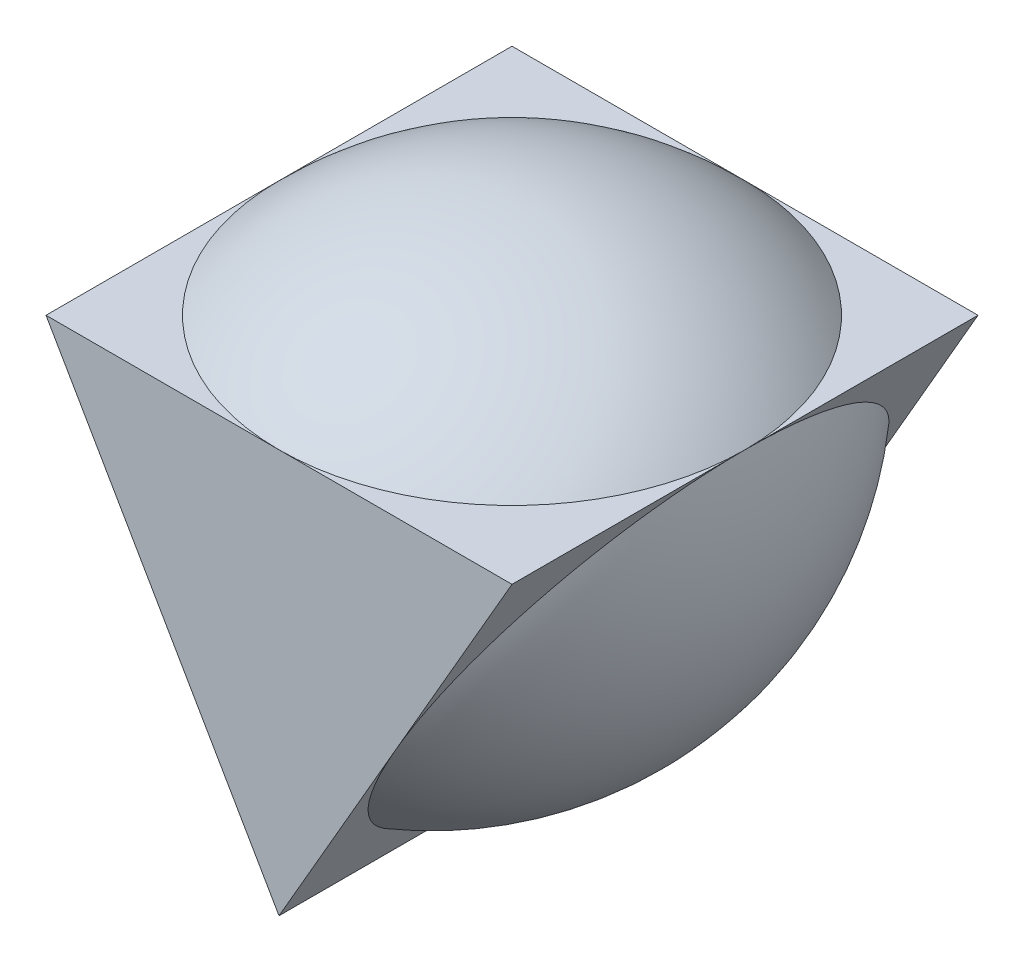
from build123d import *

# Parameters (mm, degrees)
BOSS_EXTRUDE1_DEPTH      = 10
BOSS_EXTRUDE1_DEPTH_BACK = 10
CIRPATTERN1_COUNT        = 3


with BuildPart() as part:
    # Sketch2 → Boss-Extrude1 (new, two sides: drawn at the far end of the back side and taken through both)
    with BuildSketch(Plane.XY.offset(-BOSS_EXTRUDE1_DEPTH_BACK)):
        Polygon((0, 5.773502692), (-10, 5.773502692), (0, -11.547005384), (10, 5.773502692), align=None)
    extrude(amount=BOSS_EXTRUDE1_DEPTH + BOSS_EXTRUDE1_DEPTH_BACK)

    # Sketch2_7 → Revolve3 (revolve)
    with BuildSketch(Plane.XY):
        with BuildLine():
            Line((0, 9.982895082), (0, 5.773502692))
            Line((0, 5.773502692), (10, 5.773502692))
            ThreePointArc((10, 5.773502692), (5.424918992, 8.887653347), (0, 9.982895082))
        make_face()
    revolve3 = revolve(axis=Axis((0, 9.982895082, 0), (0, -1, 0)))

    # CirPattern1: Revolve3 ×3 about axis
    cirpattern1_axis = Axis((0, 0, -10), (0, 0, -1))
    for i in range(1, CIRPATTERN1_COUNT):
        add(revolve3.rotate(cirpattern1_axis, i * 360 / CIRPATTERN1_COUNT))


solid = part.part
